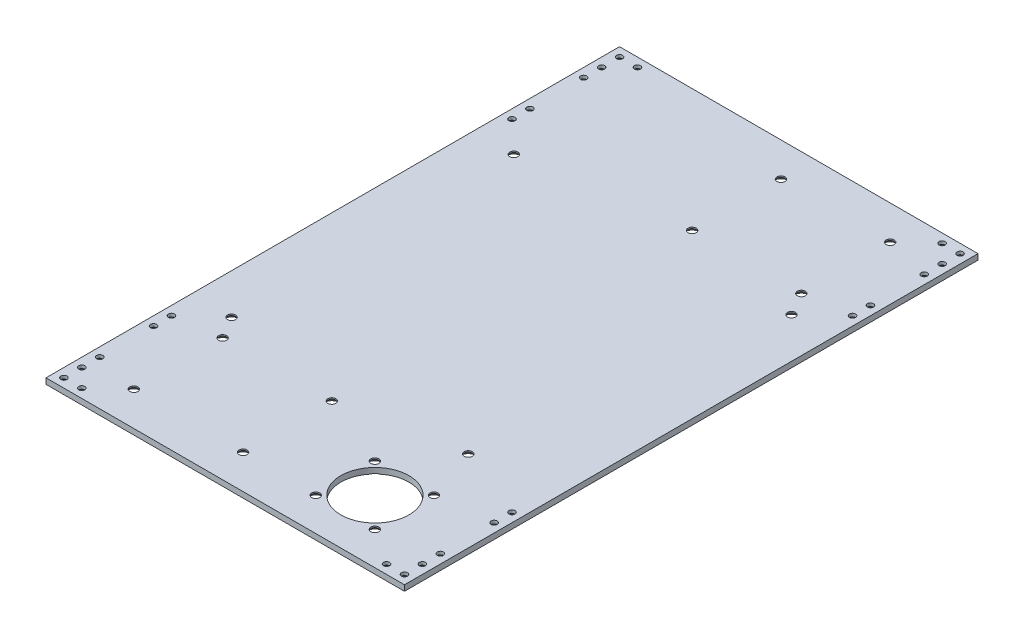
from build123d import *

# Parameters (mm, degrees)
SKETCH1_W                                       = 200
SKETCH1_H                                       = 320
BOSS_EXTRUDE1_DEPTH                             = 3.175
CSK_FOR_M3_FLAT_HEAD_MACHINE_SCREW1_D           = 3.4
CSK_FOR_M3_FLAT_HEAD_MACHINE_SCREW1_CSINK_D     = 6.3
CSK_FOR_M3_FLAT_HEAD_MACHINE_SCREW1_CSINK_ANGLE = 90
MIRROR2_COPY_1_D                                = 3.4
MIRROR2_COPY_1_CSINK_D                          = 6.3
MIRROR2_COPY_1_CSINK_ANGLE                      = 90
CSK_FOR_M4_FLAT_HEAD_MACHINE_SCREW1_AT_2_COUNT  = 2
CSK_FOR_M4_FLAT_HEAD_MACHINE_SCREW1_AT_2_PITCH  = 64.709214954
CSK_FOR_M4_FLAT_HEAD_MACHINE_SCREW1_AT_3_COUNT  = 2
CSK_FOR_M4_FLAT_HEAD_MACHINE_SCREW1_AT_3_PITCH  = 44.433123905
CSK_FOR_M4_FLAT_HEAD_MACHINE_SCREW1_AT_4_COUNT  = 2
CSK_FOR_M4_FLAT_HEAD_MACHINE_SCREW1_AT_4_PITCH  = 75.973301231
CSK_FOR_M4_FLAT_HEAD_MACHINE_SCREW1_AT_5_COUNT  = 2
CSK_FOR_M4_FLAT_HEAD_MACHINE_SCREW1_AT_5_PITCH  = 78.545162168
CSK_FOR_M4_FLAT_HEAD_MACHINE_SCREW1_AT_6_COUNT  = 2
CSK_FOR_M4_FLAT_HEAD_MACHINE_SCREW1_AT_6_PITCH  = 60.96
CSK_FOR_M4_FLAT_HEAD_MACHINE_SCREW1_AT_7_COUNT  = 2
CSK_FOR_M4_FLAT_HEAD_MACHINE_SCREW1_AT_7_PITCH  = 49.53
CSK_FOR_M4_FLAT_HEAD_MACHINE_SCREW1_AT_8_COUNT  = 2
CSK_FOR_M4_FLAT_HEAD_MACHINE_SCREW1_AT_8_PITCH  = 89.358393562
CSK_FOR_M4_FLAT_HEAD_MACHINE_SCREW1_AT_9_COUNT  = 2
CSK_FOR_M4_FLAT_HEAD_MACHINE_SCREW1_AT_9_PITCH  = 245.539452023
CSK_FOR_M4_FLAT_HEAD_MACHINE_SCREW1_AT_1_COUNT  = 2
CSK_FOR_M4_FLAT_HEAD_MACHINE_SCREW1_AT_1_PITCH  = 233.172012257
CSK_FOR_M4_FLAT_HEAD_MACHINE_SCREW1_2_COUNT     = 2
CSK_FOR_M4_FLAT_HEAD_MACHINE_SCREW1_2_PITCH     = 183.831254144
CSK_FOR_M4_FLAT_HEAD_MACHINE_SCREW1_3_COUNT     = 2
CSK_FOR_M4_FLAT_HEAD_MACHINE_SCREW1_3_PITCH     = 199.284633627
CSK_FOR_M4_FLAT_HEAD_MACHINE_SCREW1_4_COUNT     = 2
CSK_FOR_M4_FLAT_HEAD_MACHINE_SCREW1_4_PITCH     = 64.860029294
CSK_FOR_M4_FLAT_HEAD_MACHINE_SCREW1_5_COUNT     = 2
CSK_FOR_M4_FLAT_HEAD_MACHINE_SCREW1_5_PITCH     = 190.701291553
CSK_FOR_M4_FLAT_HEAD_MACHINE_SCREW1_6_COUNT     = 2
CSK_FOR_M4_FLAT_HEAD_MACHINE_SCREW1_6_PITCH     = 183.209354019
CSK_FOR_M4_FLAT_HEAD_MACHINE_SCREW1_7_COUNT     = 2
CSK_FOR_M4_FLAT_HEAD_MACHINE_SCREW1_7_PITCH     = 69.556924889
SKETCH8_R                                       = 19
CUT_EXTRUDE1_DEPTH                              = 4.175


with BuildPart() as part:
    # Sketch1 → Boss-Extrude1 (new body)
    with BuildSketch(Plane(origin=(0, 0, 0), x_dir=(1, 0, 0), z_dir=(0, 1, 0))):
        Rectangle(SKETCH1_W, SKETCH1_H)
    extrude(amount=BOSS_EXTRUDE1_DEPTH)

    # CSK for M3 Flat Head Machine Screw1 (through all)
    with Locations(Plane.XZ):
        with Locations((-95, 155), (-85, 155), (-95, 145), (-95, 135), (-95, 105), (-95, 95)):
            csk_for_m3_flat_head_machine_screw1 = CounterSinkHole(CSK_FOR_M3_FLAT_HEAD_MACHINE_SCREW1_D / 2, CSK_FOR_M3_FLAT_HEAD_MACHINE_SCREW1_CSINK_D / 2, counter_sink_angle=CSK_FOR_M3_FLAT_HEAD_MACHINE_SCREW1_CSINK_ANGLE)

    # Mirror1: CSK for M3 Flat Head Machine Screw1 across plane
    add(csk_for_m3_flat_head_machine_screw1.mirror(Plane(origin=(0, 0, 0), x_dir=(0, 0, 1), z_dir=(1, 0, 0))), mode=Mode.SUBTRACT)

    # Mirror2: CSK for M3 Flat Head Machine Screw1 across plane
    add(csk_for_m3_flat_head_machine_screw1.mirror(Plane.XY), mode=Mode.SUBTRACT)

    # Mirror2 copy 1 (through all)
    with Locations(Plane(origin=(0, 0, 0), x_dir=(-1, 0, 0), z_dir=(0, -1, 0))):
        with Locations((-95, 155), (-85, 155), (-95, 145), (-95, 135), (-95, 105), (-95, 95)):
            CounterSinkHole(MIRROR2_COPY_1_D / 2, MIRROR2_COPY_1_CSINK_D / 2, counter_sink_angle=MIRROR2_COPY_1_CSINK_ANGLE)

    # Sketch6 → CSK for M4 Flat Head Machine Screw1 (revolve, cut)
    with BuildSketch(Plane(origin=(-9.04, 0, 91.47), x_dir=(0, 0, -1), z_dir=(1, 0, 0))):
        Polygon((0, 0), (0, 3.175), (2.25, 3.175), (2.25, 2.45), (4.7, 0), align=None)
    csk_for_m4_flat_head_machine_screw1 = revolve(axis=Axis((-9.04, -6.35, 91.47), (0, 1, 0)), mode=Mode.SUBTRACT)

    # CSK for M4 Flat Head Machine Screw1 at 2: CSK for M4 Flat Head Machine Screw1 ×2
    with Locations(*[Vector(0.634221881, 0, 0.773151089) * (i * CSK_FOR_M4_FLAT_HEAD_MACHINE_SCREW1_AT_2_PITCH) for i in range(1, CSK_FOR_M4_FLAT_HEAD_MACHINE_SCREW1_AT_2_COUNT)]):
        add(csk_for_m4_flat_head_machine_screw1, mode=Mode.SUBTRACT)

    # CSK for M4 Flat Head Machine Screw1 at 3: CSK for M4 Flat Head Machine Screw1 ×2
    with Locations(*[Vector(0.923635261, 0, 0.383272624) * (i * CSK_FOR_M4_FLAT_HEAD_MACHINE_SCREW1_AT_3_PITCH) for i in range(1, CSK_FOR_M4_FLAT_HEAD_MACHINE_SCREW1_AT_3_COUNT)]):
        add(csk_for_m4_flat_head_machine_screw1, mode=Mode.SUBTRACT)

    # CSK for M4 Flat Head Machine Screw1 at 4: CSK for M4 Flat Head Machine Screw1 ×2
    with Locations(*[Vector(0.974552886, 0, 0.224157694) * (i * CSK_FOR_M4_FLAT_HEAD_MACHINE_SCREW1_AT_4_PITCH) for i in range(1, CSK_FOR_M4_FLAT_HEAD_MACHINE_SCREW1_AT_4_COUNT)]):
        add(csk_for_m4_flat_head_machine_screw1, mode=Mode.SUBTRACT)

    # CSK for M4 Flat Head Machine Screw1 at 5: CSK for M4 Flat Head Machine Screw1 ×2
    with Locations(*[Vector(-0.776114, 0, 0.630592625) * (i * CSK_FOR_M4_FLAT_HEAD_MACHINE_SCREW1_AT_5_PITCH) for i in range(1, CSK_FOR_M4_FLAT_HEAD_MACHINE_SCREW1_AT_5_COUNT)]):
        add(csk_for_m4_flat_head_machine_screw1, mode=Mode.SUBTRACT)

    # CSK for M4 Flat Head Machine Screw1 at 6: CSK for M4 Flat Head Machine Screw1 ×2
    with Locations(*[(-i * CSK_FOR_M4_FLAT_HEAD_MACHINE_SCREW1_AT_6_PITCH, 0, 0) for i in range(1, CSK_FOR_M4_FLAT_HEAD_MACHINE_SCREW1_AT_6_COUNT)]):
        add(csk_for_m4_flat_head_machine_screw1, mode=Mode.SUBTRACT)

    # CSK for M4 Flat Head Machine Screw1 at 7: CSK for M4 Flat Head Machine Screw1 ×2
    with Locations(*[(0, 0, i * CSK_FOR_M4_FLAT_HEAD_MACHINE_SCREW1_AT_7_PITCH) for i in range(1, CSK_FOR_M4_FLAT_HEAD_MACHINE_SCREW1_AT_7_COUNT)]):
        add(csk_for_m4_flat_head_machine_screw1, mode=Mode.SUBTRACT)

    # CSK for M4 Flat Head Machine Screw1 at 8: CSK for M4 Flat Head Machine Screw1 ×2
    with Locations(*[Vector(0.828573535, 0, 0.559880253) * (i * CSK_FOR_M4_FLAT_HEAD_MACHINE_SCREW1_AT_8_PITCH) for i in range(1, CSK_FOR_M4_FLAT_HEAD_MACHINE_SCREW1_AT_8_COUNT)]):
        add(csk_for_m4_flat_head_machine_screw1, mode=Mode.SUBTRACT)

    # CSK for M4 Flat Head Machine Screw1 at 9: CSK for M4 Flat Head Machine Screw1 ×2
    with Locations(*[Vector(0.321903463, 0, -0.946772497) * (i * CSK_FOR_M4_FLAT_HEAD_MACHINE_SCREW1_AT_9_PITCH) for i in range(1, CSK_FOR_M4_FLAT_HEAD_MACHINE_SCREW1_AT_9_COUNT)]):
        add(csk_for_m4_flat_head_machine_screw1, mode=Mode.SUBTRACT)

    # CSK for M4 Flat Head Machine Screw1 at 1: CSK for M4 Flat Head Machine Screw1 ×2
    with Locations(*[Vector(0.077539323, 0, -0.996989295) * (i * CSK_FOR_M4_FLAT_HEAD_MACHINE_SCREW1_AT_1_PITCH) for i in range(1, CSK_FOR_M4_FLAT_HEAD_MACHINE_SCREW1_AT_1_COUNT)]):
        add(csk_for_m4_flat_head_machine_screw1, mode=Mode.SUBTRACT)

    # CSK for M4 Flat Head Machine Screw1  2: CSK for M4 Flat Head Machine Screw1 ×2
    with Locations(*[Vector(0.098351067, 0, -0.995151781) * (i * CSK_FOR_M4_FLAT_HEAD_MACHINE_SCREW1_2_PITCH) for i in range(1, CSK_FOR_M4_FLAT_HEAD_MACHINE_SCREW1_2_COUNT)]):
        add(csk_for_m4_flat_head_machine_screw1, mode=Mode.SUBTRACT)

    # CSK for M4 Flat Head Machine Screw1  3: CSK for M4 Flat Head Machine Screw1 ×2
    with Locations(*[Vector(0.396618638, 0, -0.917983473) * (i * CSK_FOR_M4_FLAT_HEAD_MACHINE_SCREW1_3_PITCH) for i in range(1, CSK_FOR_M4_FLAT_HEAD_MACHINE_SCREW1_3_COUNT)]):
        add(csk_for_m4_flat_head_machine_screw1, mode=Mode.SUBTRACT)

    # CSK for M4 Flat Head Machine Screw1  4: CSK for M4 Flat Head Machine Screw1 ×2
    with Locations(*[Vector(0.981343991, 0, -0.192260166) * (i * CSK_FOR_M4_FLAT_HEAD_MACHINE_SCREW1_4_PITCH) for i in range(1, CSK_FOR_M4_FLAT_HEAD_MACHINE_SCREW1_4_COUNT)]):
        add(csk_for_m4_flat_head_machine_screw1, mode=Mode.SUBTRACT)

    # CSK for M4 Flat Head Machine Screw1  5: CSK for M4 Flat Head Machine Screw1 ×2
    with Locations(*[Vector(0.453641395, 0, -0.891184316) * (i * CSK_FOR_M4_FLAT_HEAD_MACHINE_SCREW1_5_PITCH) for i in range(1, CSK_FOR_M4_FLAT_HEAD_MACHINE_SCREW1_5_COUNT)]):
        add(csk_for_m4_flat_head_machine_screw1, mode=Mode.SUBTRACT)

    # CSK for M4 Flat Head Machine Screw1  6: CSK for M4 Flat Head Machine Screw1 ×2
    with Locations(*[Vector(-0.37350713, 0, -0.927627309) * (i * CSK_FOR_M4_FLAT_HEAD_MACHINE_SCREW1_6_PITCH) for i in range(1, CSK_FOR_M4_FLAT_HEAD_MACHINE_SCREW1_6_COUNT)]):
        add(csk_for_m4_flat_head_machine_screw1, mode=Mode.SUBTRACT)

    # CSK for M4 Flat Head Machine Screw1  7: CSK for M4 Flat Head Machine Screw1 ×2
    with Locations(*[Vector(-0.983798523, 0, -0.179277621) * (i * CSK_FOR_M4_FLAT_HEAD_MACHINE_SCREW1_7_PITCH) for i in range(1, CSK_FOR_M4_FLAT_HEAD_MACHINE_SCREW1_7_COUNT)]):
        add(csk_for_m4_flat_head_machine_screw1, mode=Mode.SUBTRACT)

    # Sketch8 → Cut-Extrude1 (cut, through all)
    with BuildSketch(Plane(origin=(0, 3.175, 0), x_dir=(1, 0, 0), z_dir=(0, 1, 0))):
        with Locations((48.5, -125)):
            Circle(SKETCH8_R)
    extrude(amount=-CUT_EXTRUDE1_DEPTH, mode=Mode.SUBTRACT)


solid = part.part
